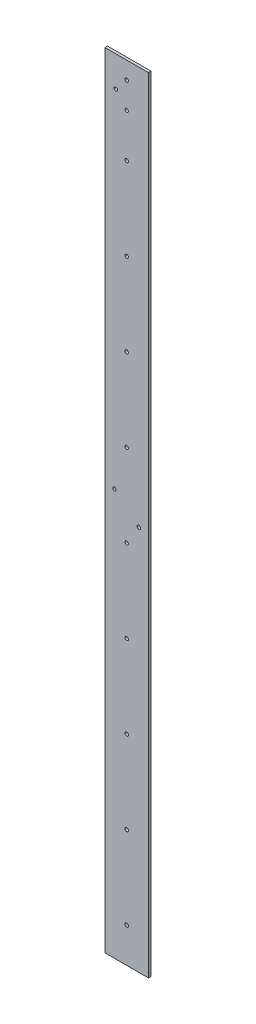
from build123d import *

# Parameters (mm, degrees)
SKETCH2_W           = 50
SKETCH2_H           = 900
BOSS_EXTRUDE1_DEPTH = 3
CUT_EXTRUDE1_REACH  = 5
SKETCH3_R           = 2


with BuildPart() as part:
    # Sketch2 → Boss-Extrude1 (new body)
    with BuildSketch(Plane.XY):
        with Locations((0.371961745, 0.278971309)):
            Rectangle(SKETCH2_W, SKETCH2_H)
    extrude(amount=BOSS_EXTRUDE1_DEPTH)

    # Sketch3 → Cut-Extrude1 (cut, up to next)
    with BuildSketch(Plane.XY.offset(3), mode=Mode.PRIVATE) as cut_extrude1_sk1:
        with Locations((0.371961745, 350.278971308)):
            Circle(SKETCH3_R)
    cut_extrude1_tool1 = extrude(cut_extrude1_sk1.sketch, amount=-CUT_EXTRUDE1_REACH, mode=Mode.PRIVATE) & part.part
    add(cut_extrude1_tool1.solids().sort_by_distance((0.371962, 350.278971, 3))[0], mode=Mode.SUBTRACT)
    # Sketch3 → Cut-Extrude1 (cut, up to next)
    with BuildSketch(Plane.XY.offset(3), mode=Mode.PRIVATE) as cut_extrude1_sk2:
        with Locations((0.371961745, 400.278971308)):
            Circle(SKETCH3_R)
    cut_extrude1_tool2 = extrude(cut_extrude1_sk2.sketch, amount=-CUT_EXTRUDE1_REACH, mode=Mode.PRIVATE) & part.part
    add(cut_extrude1_tool2.solids().sort_by_distance((0.371962, 400.278971, 3))[0], mode=Mode.SUBTRACT)
    # Sketch3 → Cut-Extrude1 (cut, up to next)
    with BuildSketch(Plane.XY.offset(3), mode=Mode.PRIVATE) as cut_extrude1_sk3:
        with Locations((0.371961745, 430.278971309)):
            Circle(SKETCH3_R)
    cut_extrude1_tool3 = extrude(cut_extrude1_sk3.sketch, amount=-CUT_EXTRUDE1_REACH, mode=Mode.PRIVATE) & part.part
    add(cut_extrude1_tool3.solids().sort_by_distance((0.371962, 430.278971, 3))[0], mode=Mode.SUBTRACT)
    # Sketch3 → Cut-Extrude1 (cut, up to next)
    with BuildSketch(Plane.XY.offset(3), mode=Mode.PRIVATE) as cut_extrude1_sk4:
        with Locations((-12.128038255, 415.278971308)):
            Circle(SKETCH3_R)
    cut_extrude1_tool4 = extrude(cut_extrude1_sk4.sketch, amount=-CUT_EXTRUDE1_REACH, mode=Mode.PRIVATE) & part.part
    add(cut_extrude1_tool4.solids().sort_by_distance((-12.128038, 415.278971, 3))[0], mode=Mode.SUBTRACT)
    # Sketch3 → Cut-Extrude1 (cut, up to next)
    with BuildSketch(Plane.XY.offset(3), mode=Mode.PRIVATE) as cut_extrude1_sk5:
        with Locations((0.371961745, 255.278971308)):
            Circle(SKETCH3_R)
    cut_extrude1_tool5 = extrude(cut_extrude1_sk5.sketch, amount=-CUT_EXTRUDE1_REACH, mode=Mode.PRIVATE) & part.part
    add(cut_extrude1_tool5.solids().sort_by_distance((0.371962, 255.278971, 3))[0], mode=Mode.SUBTRACT)
    # Sketch3 → Cut-Extrude1 (cut, up to next)
    with BuildSketch(Plane.XY.offset(3), mode=Mode.PRIVATE) as cut_extrude1_sk6:
        with Locations((0.371961745, 160.278971308)):
            Circle(SKETCH3_R)
    cut_extrude1_tool6 = extrude(cut_extrude1_sk6.sketch, amount=-CUT_EXTRUDE1_REACH, mode=Mode.PRIVATE) & part.part
    add(cut_extrude1_tool6.solids().sort_by_distance((0.371962, 160.278971, 3))[0], mode=Mode.SUBTRACT)
    # Sketch3 → Cut-Extrude1 (cut, up to next)
    with BuildSketch(Plane.XY.offset(3), mode=Mode.PRIVATE) as cut_extrude1_sk7:
        with Locations((0.371961745, 65.278971308)):
            Circle(SKETCH3_R)
    cut_extrude1_tool7 = extrude(cut_extrude1_sk7.sketch, amount=-CUT_EXTRUDE1_REACH, mode=Mode.PRIVATE) & part.part
    add(cut_extrude1_tool7.solids().sort_by_distance((0.371962, 65.278971, 3))[0], mode=Mode.SUBTRACT)
    # Sketch3 → Cut-Extrude1 (cut, up to next)
    with BuildSketch(Plane.XY.offset(3), mode=Mode.PRIVATE) as cut_extrude1_sk8:
        with Locations((0.371961745, -29.721028692)):
            Circle(SKETCH3_R)
    cut_extrude1_tool8 = extrude(cut_extrude1_sk8.sketch, amount=-CUT_EXTRUDE1_REACH, mode=Mode.PRIVATE) & part.part
    add(cut_extrude1_tool8.solids().sort_by_distance((0.371962, -29.721029, 3))[0], mode=Mode.SUBTRACT)
    # Sketch3 → Cut-Extrude1 (cut, up to next)
    with BuildSketch(Plane.XY.offset(3), mode=Mode.PRIVATE) as cut_extrude1_sk9:
        with Locations((0.371961745, -124.721028692)):
            Circle(SKETCH3_R)
    cut_extrude1_tool9 = extrude(cut_extrude1_sk9.sketch, amount=-CUT_EXTRUDE1_REACH, mode=Mode.PRIVATE) & part.part
    add(cut_extrude1_tool9.solids().sort_by_distance((0.371962, -124.721029, 3))[0], mode=Mode.SUBTRACT)
    # Sketch3 → Cut-Extrude1 (cut, up to next)
    with BuildSketch(Plane.XY.offset(3), mode=Mode.PRIVATE) as cut_extrude1_sk10:
        with Locations((0.371961745, -219.721028692)):
            Circle(SKETCH3_R)
    cut_extrude1_tool10 = extrude(cut_extrude1_sk10.sketch, amount=-CUT_EXTRUDE1_REACH, mode=Mode.PRIVATE) & part.part
    add(cut_extrude1_tool10.solids().sort_by_distance((0.371962, -219.721029, 3))[0], mode=Mode.SUBTRACT)
    # Sketch3 → Cut-Extrude1 (cut, up to next)
    with BuildSketch(Plane.XY.offset(3), mode=Mode.PRIVATE) as cut_extrude1_sk11:
        with Locations((0.371961745, -314.721028692)):
            Circle(SKETCH3_R)
    cut_extrude1_tool11 = extrude(cut_extrude1_sk11.sketch, amount=-CUT_EXTRUDE1_REACH, mode=Mode.PRIVATE) & part.part
    add(cut_extrude1_tool11.solids().sort_by_distance((0.371962, -314.721029, 3))[0], mode=Mode.SUBTRACT)
    # Sketch3 → Cut-Extrude1 (cut, up to next)
    with BuildSketch(Plane.XY.offset(3), mode=Mode.PRIVATE) as cut_extrude1_sk12:
        with Locations((0.371961745, -409.721028692)):
            Circle(SKETCH3_R)
    cut_extrude1_tool12 = extrude(cut_extrude1_sk12.sketch, amount=-CUT_EXTRUDE1_REACH, mode=Mode.PRIVATE) & part.part
    add(cut_extrude1_tool12.solids().sort_by_distance((0.371962, -409.721029, 3))[0], mode=Mode.SUBTRACT)
    # Sketch3 → Cut-Extrude1 (cut, up to next)
    with BuildSketch(Plane.XY.offset(3), mode=Mode.PRIVATE) as cut_extrude1_sk13:
        with Locations((14.371961745, -7.200910707)):
            Circle(SKETCH3_R)
    cut_extrude1_tool13 = extrude(cut_extrude1_sk13.sketch, amount=-CUT_EXTRUDE1_REACH, mode=Mode.PRIVATE) & part.part
    add(cut_extrude1_tool13.solids().sort_by_distance((14.371962, -7.200911, 3))[0], mode=Mode.SUBTRACT)
    # Sketch3 → Cut-Extrude1 (cut, up to next)
    with BuildSketch(Plane.XY.offset(3), mode=Mode.PRIVATE) as cut_extrude1_sk14:
        with Locations((-13.628038255, 16.927507875)):
            Circle(SKETCH3_R)
    cut_extrude1_tool14 = extrude(cut_extrude1_sk14.sketch, amount=-CUT_EXTRUDE1_REACH, mode=Mode.PRIVATE) & part.part
    add(cut_extrude1_tool14.solids().sort_by_distance((-13.628038, 16.927508, 3))[0], mode=Mode.SUBTRACT)


solid = part.part
